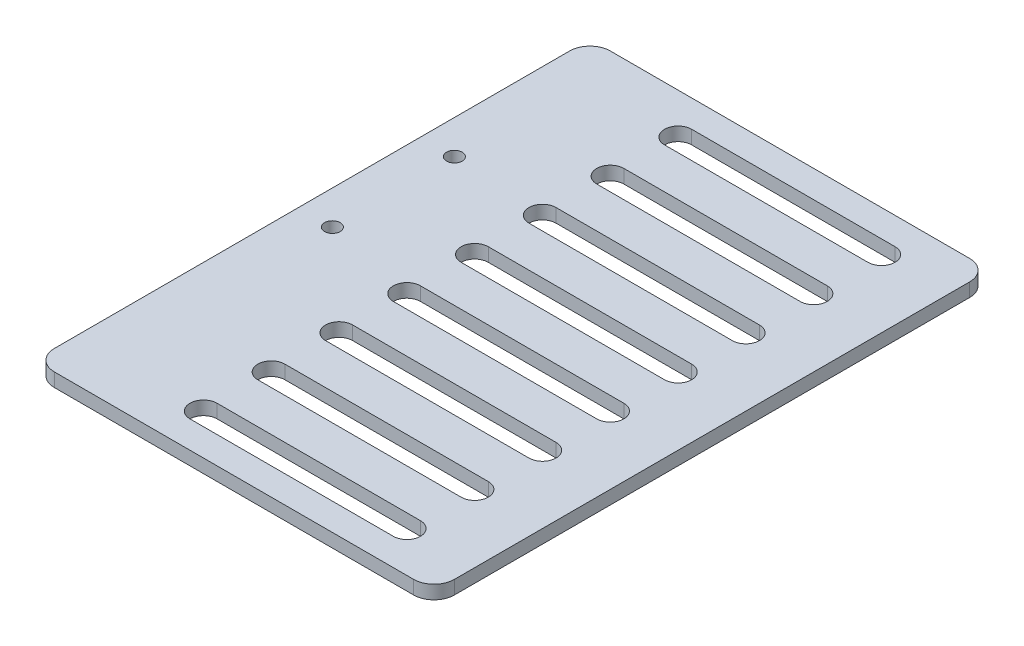
from build123d import *

# Parameters (mm, degrees)
SKETCH_1_R          = 1.15
EXTRUDE_1_DEPTH     = 2
FILLET_1_R          = 3
SKETCH_2_R          = 1.15
CUT_EXTRUDE_1_DEPTH = 2
SKETCH_3_W          = 9
SKETCH_3_H          = 30
CUT_EXTRUDE_2_DEPTH = 2
CUT_EXTRUDE_3_DEPTH = 3


with BuildPart() as part:
    # 草图1 → 凸台-拉伸1 (new body)
    with BuildSketch(Plane(origin=(0, 0, 0), x_dir=(1, 0, 0), z_dir=(0, 1, 0))):
        Polygon((64, -39), (5, -39), (5, -3), (-4, -3), (-4, 21), (5, 21), (5, 43), (64, 43), align=None)
        Circle(SKETCH_1_R, mode=Mode.SUBTRACT)
        with Locations((0, 18)):
            Circle(SKETCH_1_R, mode=Mode.SUBTRACT)
    extrude(amount=EXTRUDE_1_DEPTH)

    # 圆角1
    fillet_1_edges = [part.edges().sort_by_distance(p)[0] for p in [
        (5, 1, -43),
        (64, 1, -43),
        (64, 1, 39),
        (5, 1, 39),
        (5, 1, 3),
        (-4, 1, 3),
        (-4, 1, -21),
        (5, 1, -21),
    ]]
    fillet(fillet_1_edges, radius=FILLET_1_R)

    # 草图2 → 切除-拉伸1 (cut)
    with BuildSketch(Plane(origin=(0, 2, 0), x_dir=(1, 0, 0), z_dir=(0, 1, 0))):
        with Locations((10, 18)):
            Circle(SKETCH_2_R)
        with Locations((10, 0)):
            Circle(SKETCH_2_R)
    extrude(amount=-CUT_EXTRUDE_1_DEPTH, mode=Mode.SUBTRACT)

    # 草图3 → 切除-拉伸2 (cut)
    with BuildSketch(Plane(origin=(0, 2, 0), x_dir=(1, 0, 0), z_dir=(0, 1, 0))):
        with Locations((0.5, 9)):
            Rectangle(SKETCH_3_W, SKETCH_3_H)
    extrude(amount=-CUT_EXTRUDE_2_DEPTH, mode=Mode.SUBTRACT)

    # 草图4 → 切除-拉伸3 (cut, through all)
    with BuildSketch(Plane(origin=(0, 2, 0), x_dir=(1, 0, 0), z_dir=(0, 1, 0))):
        with BuildLine():
            Line((24, 39), (54, 39))
            ThreePointArc((54, 39), (56, 37), (54, 35))
            Line((54, 35), (24, 35))
            ThreePointArc((24, 35), (22, 37), (24, 39))
        make_face()
        with BuildLine():
            Line((24, 29), (54, 29))
            ThreePointArc((54, 29), (56, 27), (54, 25))
            Line((54, 25), (24, 25))
            ThreePointArc((24, 25), (22, 27), (24, 29))
        make_face()
        with BuildLine():
            Line((24, 19), (54, 19))
            ThreePointArc((54, 19), (56, 17), (54, 15))
            Line((54, 15), (24, 15))
            ThreePointArc((24, 15), (22, 17), (24, 19))
        make_face()
        with BuildLine():
            Line((24, 9), (54, 9))
            ThreePointArc((54, 9), (56, 7), (54, 5))
            Line((54, 5), (24, 5))
            ThreePointArc((24, 5), (22, 7), (24, 9))
        make_face()
        with BuildLine():
            Line((24, -1), (54, -1))
            ThreePointArc((54, -1), (56, -3), (54, -5))
            Line((54, -5), (24, -5))
            ThreePointArc((24, -5), (22, -3), (24, -1))
        make_face()
        with BuildLine():
            Line((24, -11), (54, -11))
            ThreePointArc((54, -11), (56, -13), (54, -15))
            Line((54, -15), (24, -15))
            ThreePointArc((24, -15), (22, -13), (24, -11))
        make_face()
        with BuildLine():
            Line((24, -21), (54, -21))
            ThreePointArc((54, -21), (56, -23), (54, -25))
            Line((54, -25), (24, -25))
            ThreePointArc((24, -25), (22, -23), (24, -21))
        make_face()
        with BuildLine():
            Line((24, -31), (54, -31))
            ThreePointArc((54, -31), (56, -33), (54, -35))
            Line((54, -35), (24, -35))
            ThreePointArc((24, -35), (22, -33), (24, -31))
        make_face()
    extrude(amount=-CUT_EXTRUDE_3_DEPTH, mode=Mode.SUBTRACT)


solid = part.part
